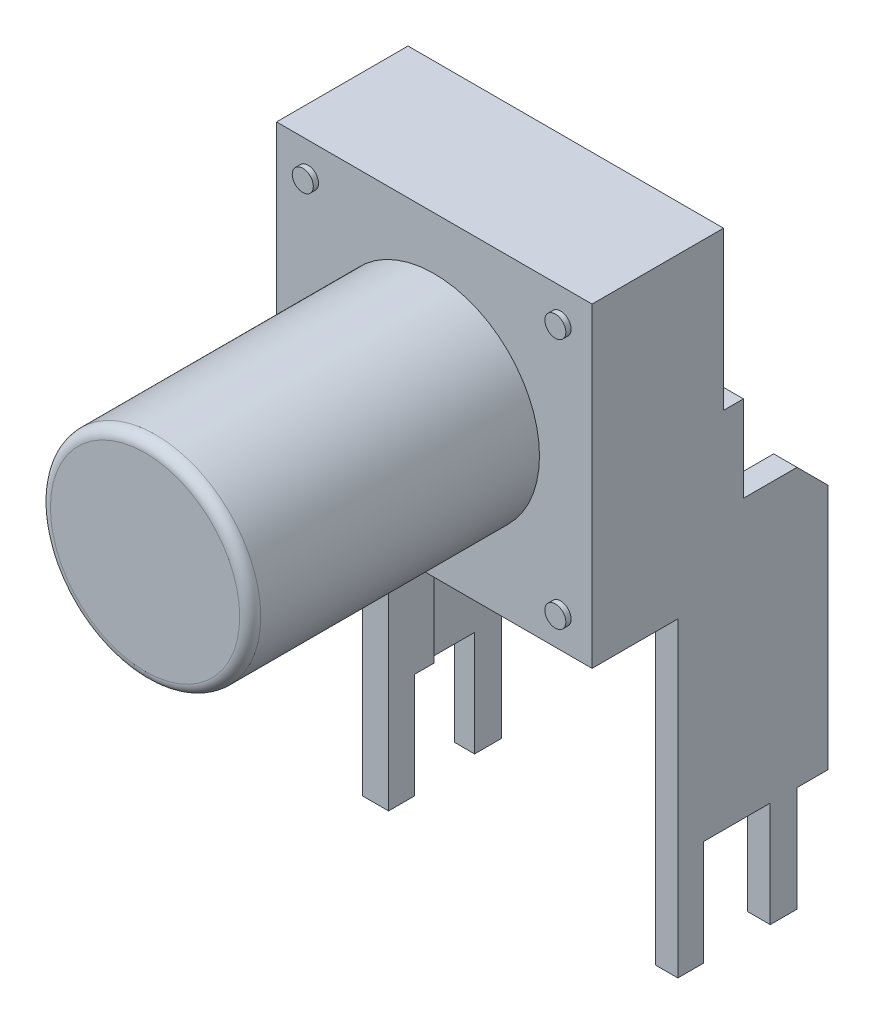
from build123d import *

# Parameters (mm, degrees)
SKETCH1_W               = 6
SKETCH1_H               = 6
BOSS_EXTRUDE1_DEPTH     = 2.5
SKETCH2_R               = 2
BOSS_EXTRUDE2_DEPTH     = 5.5
SKETCH3_R               = 0.2
BOSS_EXTRUDE3_DEPTH     = 0.1
BOSS_EXTRUDE4_DEPTH     = 6
SKETCH5_W               = 5.177961038
SKETCH5_H               = 4.130239003
CUT_EXTRUDE1_DEPTH      = 1
CUT_EXTRUDE1_DEPTH_BACK = 12.914158668
SKETCH6_W               = 5.072029737
SKETCH6_H               = 6.679255732
CUT_EXTRUDE2_DEPTH      = 8.131207494
CUT_EXTRUDE2_DEPTH_BACK = 3.853830155
FILLET1_R               = 0.2


with BuildPart() as part:
    # Sketch1 → Boss-Extrude1 (new body)
    with BuildSketch(Plane.XY):
        with Locations((3, 3)):
            Rectangle(SKETCH1_W, SKETCH1_H)
    extrude(amount=BOSS_EXTRUDE1_DEPTH)

    # Sketch3 → Boss-Extrude3 (add)
    with BuildSketch(Plane.XY.offset(2.5)):
        with Locations((0.598613773, 0.612952074)):
            Circle(SKETCH3_R)
        with Locations((5.401386227, 0.612952074)):
            Circle(SKETCH3_R)
        with Locations((5.401386227, 5.387047926)):
            Circle(SKETCH3_R)
        with Locations((0.598613773, 5.387047926)):
            Circle(SKETCH3_R)
    extrude(amount=BOSS_EXTRUDE3_DEPTH)



with BuildPart() as body_2:
    # Sketch2 → Boss-Extrude2 (new body)
    with BuildSketch(Plane.XY.offset(2.5)):
        with Locations((3, 3)):
            Circle(SKETCH2_R)
    extrude(amount=BOSS_EXTRUDE2_DEPTH)


with BuildPart() as part_1:
    add(part.part)

    add(body_2.part)  # Boss-Extrude4 merges body 2
    # Sketch4 → Boss-Extrude4 (add)
    with BuildSketch(Plane(origin=(6, 0, 0), x_dir=(0, 0, -1), z_dir=(1, 0, 0))):
        Polygon((-2.5, 3), (0.378290485, 3), (0.378290485, 1.362552045), (1.397956954, 1.362552045), (1.985037649, 0.77547135), (1.985037649, -3.91190451), (1.397956954, -3.91190451), (1.397956954, -5.914158668), (0.88812372, -5.914158668), (0.88812372, -3.91190451), (-0.379352601, -3.91190451), (-0.379352601, -5.914158668), (-0.868792506, -5.914158668), (-0.868792506, 0), (-2.5, 0), align=None)
    extrude(amount=-BOSS_EXTRUDE4_DEPTH)

    # Sketch5 → Cut-Extrude1 (cut, two sides)
    with BuildSketch(Plane(origin=(0, 6, 0), x_dir=(1, 0, 0), z_dir=(0, 1, 0))) as cut_extrude1_sk:
        with Locations((2.966920818, 2.065119502)):
            Rectangle(SKETCH5_W, SKETCH5_H)
    extrude(amount=CUT_EXTRUDE1_DEPTH, mode=Mode.SUBTRACT)
    extrude(cut_extrude1_sk.sketch, amount=-CUT_EXTRUDE1_DEPTH_BACK, mode=Mode.SUBTRACT)

    # Sketch6 → Cut-Extrude2 (cut, two sides)
    with BuildSketch(Plane.XY.offset(0.868792506)) as cut_extrude2_sk:
        with Locations((3.03473993, -3.339627866)):
            Rectangle(SKETCH6_W, SKETCH6_H)
    extrude(amount=CUT_EXTRUDE2_DEPTH, mode=Mode.SUBTRACT)
    extrude(cut_extrude2_sk.sketch, amount=-CUT_EXTRUDE2_DEPTH_BACK, mode=Mode.SUBTRACT)

    # Fillet1
    fillet1_edges = [part_1.edges().sort_by_distance(p)[0] for p in [
        (1, 3, 8),
    ]]
    fillet(fillet1_edges, radius=FILLET1_R)


solid = part_1.part
